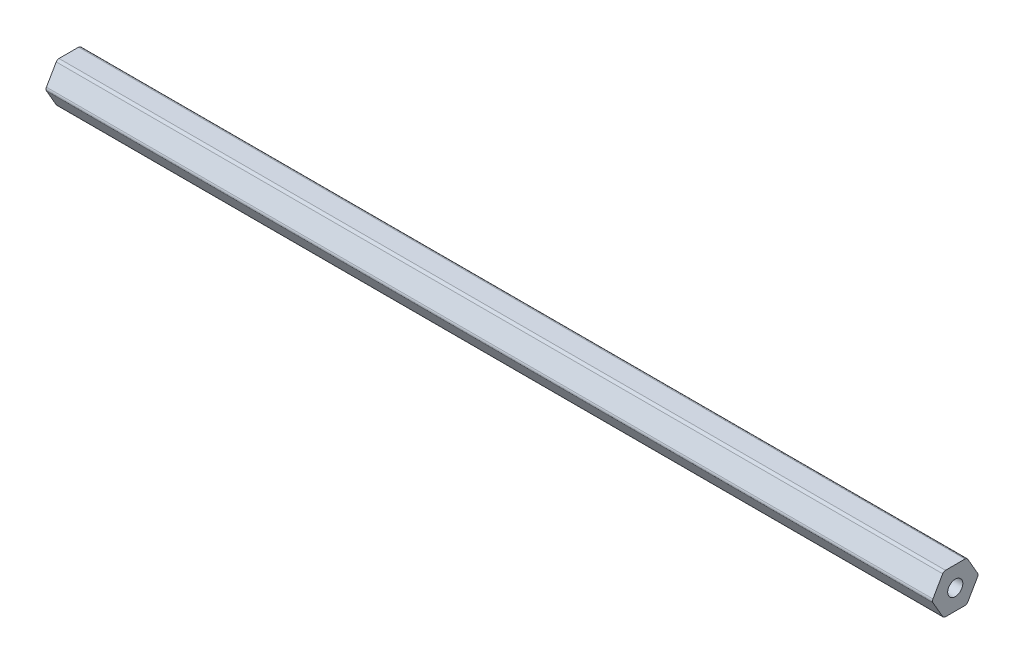
from build123d import *

# Parameters (mm, degrees)
SKETCH1_R           = 2.38125
BOSS_EXTRUDE1_DEPTH = 279.4


with BuildPart() as part:
    # Sketch1 → Boss-Extrude1 (new body)
    with BuildSketch(Plane(origin=(0, 0, 0), x_dir=(0, 0, -1), z_dir=(1, 0, 0))):
        with BuildLine():
            Line((7.039054482, 0.508), (3.959468146, 5.842))
            ThreePointArc((3.959468146, 5.842), (3.587586336, 6.21388181), (3.079586336, 6.35))
            Line((3.079586336, 6.35), (-3.079586336, 6.35))
            ThreePointArc((-3.079586336, 6.35), (-3.587586336, 6.21388181), (-3.959468146, 5.842))
            Line((-3.959468146, 5.842), (-7.039054482, 0.508))
            ThreePointArc((-7.039054482, 0.508), (-7.175172672, 0), (-7.039054482, -0.508))
            Line((-7.039054482, -0.508), (-3.959468146, -5.842))
            ThreePointArc((-3.959468146, -5.842), (-3.587586336, -6.21388181), (-3.079586336, -6.35))
            Line((-3.079586336, -6.35), (3.079586336, -6.35))
            ThreePointArc((3.079586336, -6.35), (3.587586336, -6.21388181), (3.959468146, -5.842))
            Line((3.959468146, -5.842), (7.039054482, -0.508))
            ThreePointArc((7.039054482, -0.508), (7.175172672, 0), (7.039054482, 0.508))
        make_face()
        Circle(SKETCH1_R, mode=Mode.SUBTRACT)
    extrude(amount=BOSS_EXTRUDE1_DEPTH)


solid = part.part
